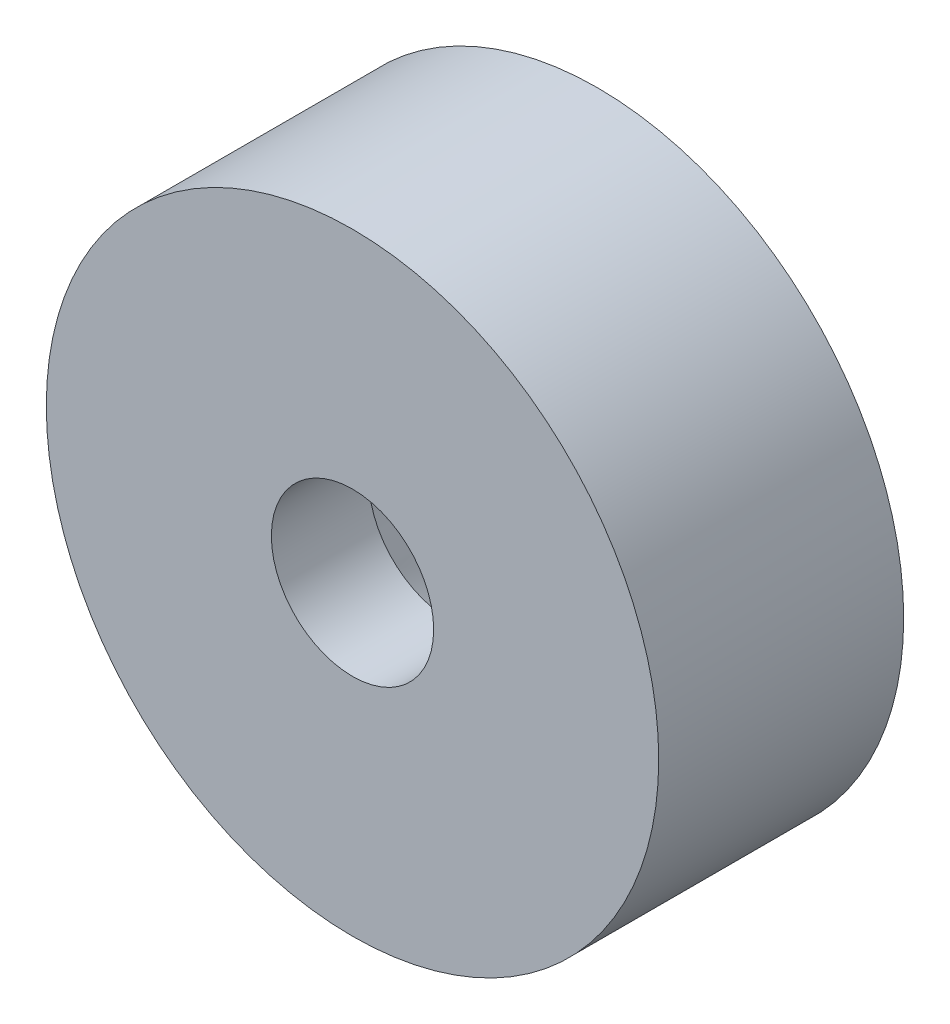
from build123d import *

# Parameters (mm, degrees)
SKETCH1_R           = 10
BOSS_EXTRUDE1_DEPTH = 8
SKETCH2_R           = 2.65
CUT_EXTRUDE1_DEPTH  = 8
SKETCH3_R           = 5
CUT_EXTRUDE2_DEPTH  = 5
CUT_EXTRUDE2_TAPER  = 26


with BuildPart() as part:
    # Sketch1 → Boss-Extrude1 (new body)
    with BuildSketch(Plane.XY):
        Circle(SKETCH1_R)
    extrude(amount=BOSS_EXTRUDE1_DEPTH)

    # Sketch2 → Cut-Extrude1 (cut)
    with BuildSketch(Plane(origin=(0, 0, 0), x_dir=(-1, 0, 0), z_dir=(0, 0, -1))):
        Circle(SKETCH2_R)
    extrude(amount=-CUT_EXTRUDE1_DEPTH, mode=Mode.SUBTRACT)

    # Sketch3 → Cut-Extrude2 (cut)
    with BuildSketch(Plane(origin=(0, 0, 0), x_dir=(-1, 0, 0), z_dir=(0, 0, -1))):
        Circle(SKETCH3_R)
    extrude(amount=-CUT_EXTRUDE2_DEPTH, taper=CUT_EXTRUDE2_TAPER, mode=Mode.SUBTRACT)


solid = part.part
